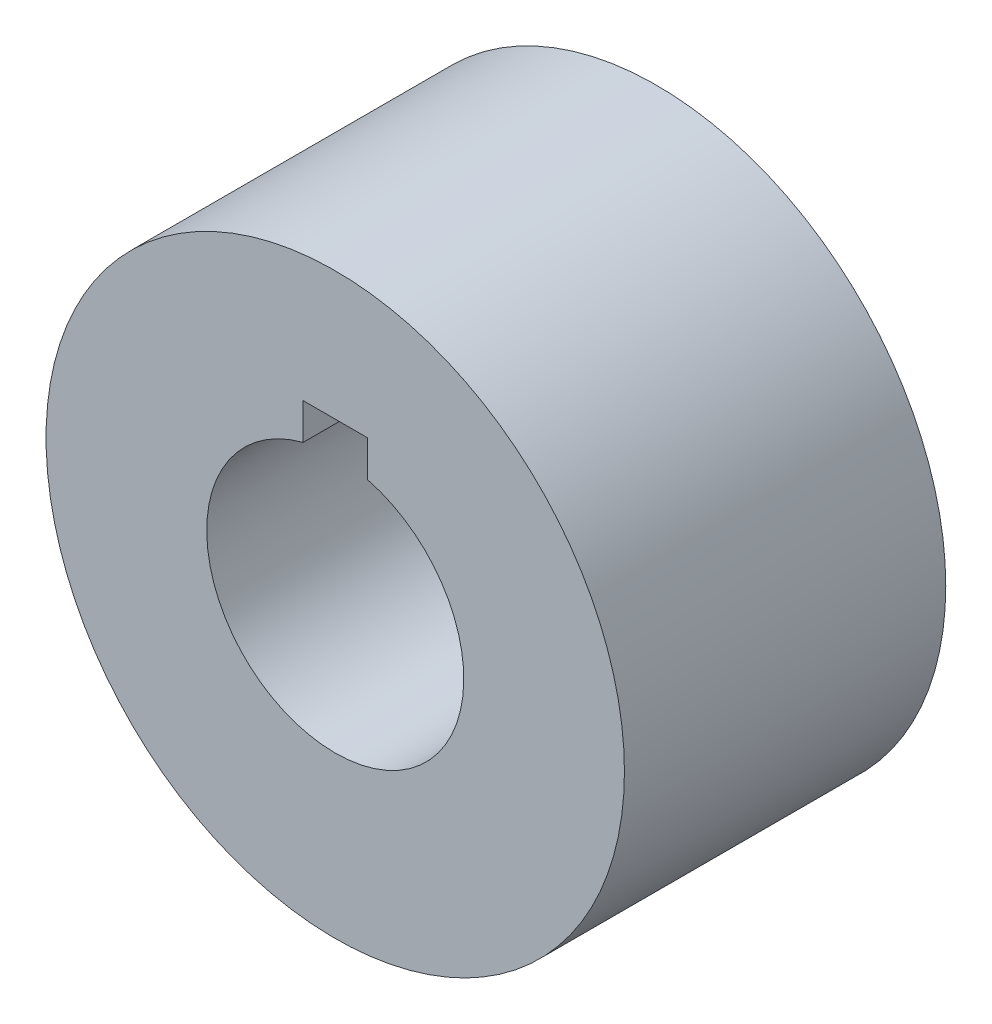
from build123d import *

# Parameters (mm, degrees)
SKETCH_1_R      = 9
EXTRUDE_1_DEPTH = 10


with BuildPart() as part:
    # ｽｹｯﾁ1 → ﾎﾞｽ - 押し出し1 (new body)
    with BuildSketch(Plane.XY):
        Circle(SKETCH_1_R)
        with BuildLine():
            Line((-1, 5), (-1, 3.872983346))
            ThreePointArc((-1, 3.872983346), (0, -4), (1, 3.872983346))
            Line((1, 3.872983346), (1, 5))
            Line((1, 5), (-1, 5))
        make_face(mode=Mode.SUBTRACT)
    extrude(amount=EXTRUDE_1_DEPTH)


solid = part.part
